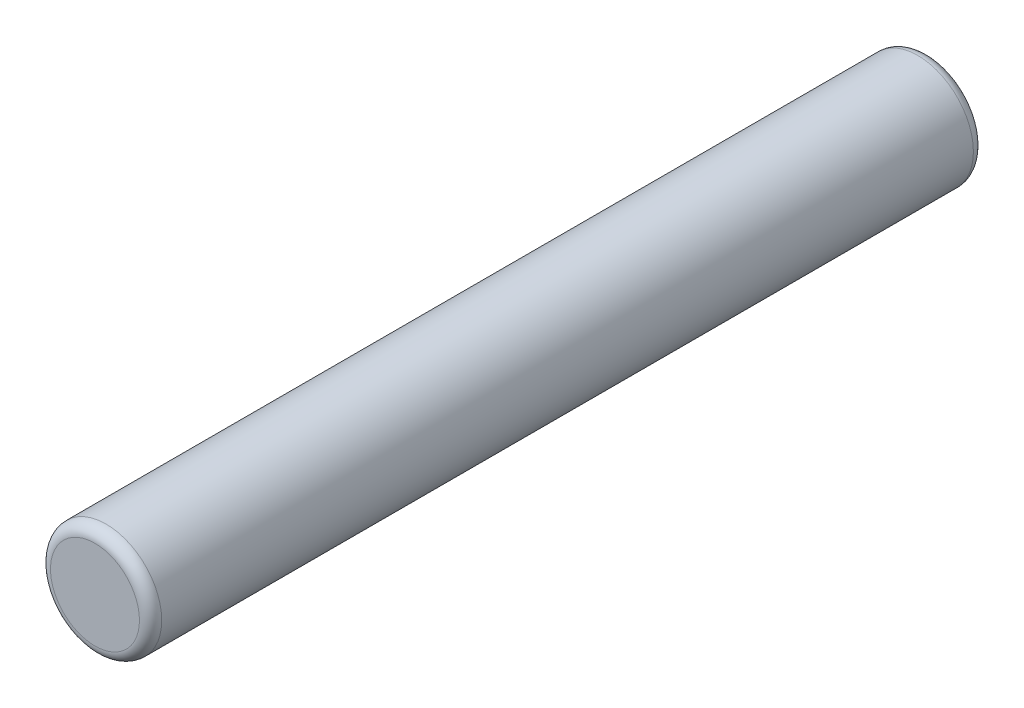
from build123d import *

# Parameters (mm, degrees)
SKETCH2_R           = 1
BOSS_EXTRUDE1_DEPTH = 15
FILLET1_R           = 0.2


with BuildPart() as part:
    # Sketch2 → Boss-Extrude1 (new body)
    with BuildSketch(Plane.XY):
        with Locations((-17.858143606, 10.947759434)):
            Circle(SKETCH2_R)
    extrude(amount=BOSS_EXTRUDE1_DEPTH)

    # Fillet1
    fillet1_edges = [part.edges().sort_by_distance(p)[0] for p in [
        (-18.858143606, 10.947759434, 0),
        (-18.858143606, 10.947759434, 15),
    ]]
    fillet(fillet1_edges, radius=FILLET1_R)


solid = part.part
